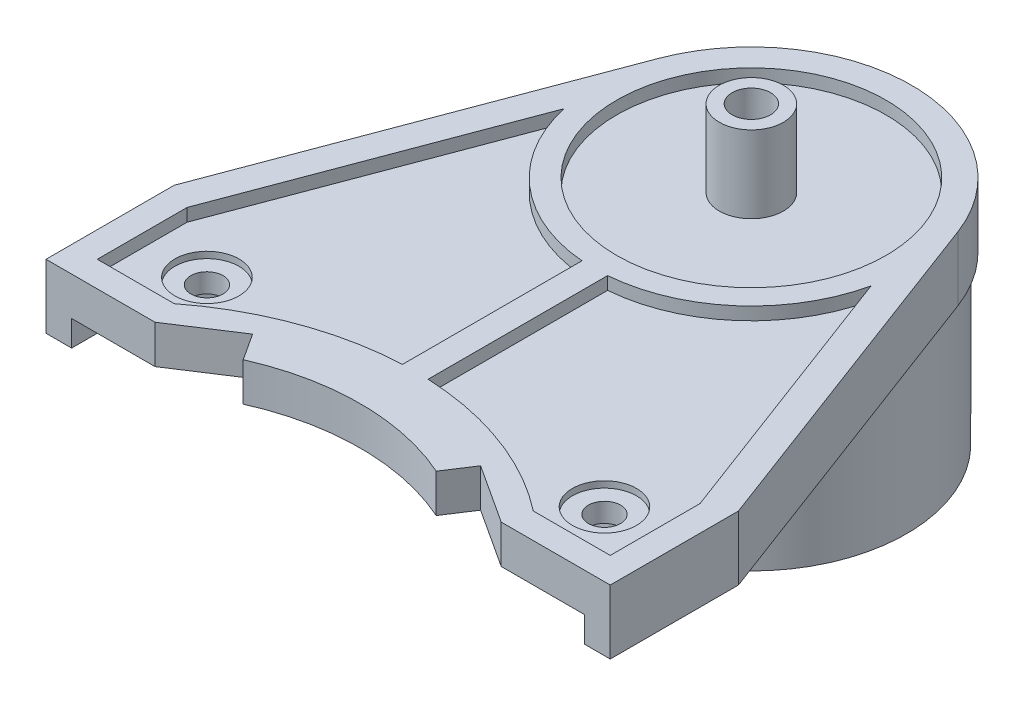
from build123d import *

# Parameters (mm, degrees)
BOSS_EXTRUDE1_DEPTH = 5
SKETCH3_R           = 10.5
CUT_EXTRUDE1_DEPTH  = 1
SKETCH4_R           = 2.5
BOSS_EXTRUDE2_DEPTH = 6
SKETCH5_R           = 1.5
CUT_EXTRUDE2_DEPTH  = 3
CUT_EXTRUDE3_DEPTH  = 1
SKETCH7_R           = 1.25
CUT_EXTRUDE4_DEPTH  = 5
SKETCH8_R           = 2.5
CUT_EXTRUDE5_DEPTH  = 0.5
CUT_EXTRUDE6_DEPTH  = 2
CUT_EXTRUDE7_DEPTH  = 2
SKETCH12_R          = 12.1
BOSS_EXTRUDE3_DEPTH = 15
SKETCH13_R          = 10.4
SKETCH13_R_2        = 2.5
CUT_EXTRUDE8_DEPTH  = 14
SKETCH14_R          = 1.5
CUT_EXTRUDE9_DEPTH  = 5


with BuildPart() as part:
    # Sketch1 → Boss-Extrude1 (new body)
    with BuildSketch(Plane(origin=(0, 0, 0), x_dir=(1, 0, 0), z_dir=(0, 1, 0))):
        with BuildLine():
            Line((-22, -23.004932369), (-22, -33.004932369))
            Line((-22, -33.004932369), (-13.5, -33.004932369))
            Line((-13.5, -33.004932369), (-8.890227771, -30.004932369))
            Line((-8.890227771, -30.004932369), (-7.526591408, -32.100283382))
            ThreePointArc((-7.526591408, -32.100283382), (-3.847417482, -30.904492858), (0, -30.5))
            Line((0, -30.5), (0, 12.5))
            ThreePointArc((0, 12.5), (-7.116131574, 10.276705281), (-11.700861907, 4.397707428))
            Line((-11.700861907, 4.397707428), (-22, -23.004932369))
        make_face()
        with BuildLine():
            ThreePointArc((11.700861907, 4.397707428), (7.116131574, 10.276705281), (0, 12.5))
            Line((0, 12.5), (0, -30.5))
            ThreePointArc((0, -30.5), (3.847417482, -30.904492858), (7.526591408, -32.100283382))
            Line((7.526591408, -32.100283382), (8.890227771, -30.004932369))
            Line((8.890227771, -30.004932369), (13.5, -33.004932369))
            Line((13.5, -33.004932369), (22, -33.004932369))
            Line((22, -33.004932369), (22, -23.004932369))
            Line((22, -23.004932369), (11.700861907, 4.397707428))
        make_face()
    extrude(amount=BOSS_EXTRUDE1_DEPTH)

    # Sketch3 → Cut-Extrude1 (cut)
    with BuildSketch(Plane(origin=(0, 5, 0), x_dir=(1, 0, 0), z_dir=(0, 1, 0))):
        Circle(SKETCH3_R)
    extrude(amount=-CUT_EXTRUDE1_DEPTH, mode=Mode.SUBTRACT)

    # Sketch4 → Boss-Extrude2 (add)
    with BuildSketch(Plane(origin=(0, 4, 0), x_dir=(1, 0, 0), z_dir=(0, 1, 0))):
        Circle(SKETCH4_R)
    extrude(amount=BOSS_EXTRUDE2_DEPTH)

    # Sketch5 → Cut-Extrude2 (cut)
    with BuildSketch(Plane(origin=(0, 10, 0), x_dir=(1, 0, 0), z_dir=(0, 1, 0))):
        Circle(SKETCH5_R)
    extrude(amount=-CUT_EXTRUDE2_DEPTH, mode=Mode.SUBTRACT)

    # Sketch6 → Cut-Extrude3 (cut)
    with BuildSketch(Plane(origin=(0, 5, 0), x_dir=(1, 0, 0), z_dir=(0, 1, 0))):
        with BuildLine():
            Line((-1, -12.209115447), (-1, -26.209115447))
            ThreePointArc((-1, -26.209115447), (-7.874005651, -27.593208423), (-14, -31.004932369))
            Line((-14, -31.004932369), (-20, -31.004932369))
            Line((-20, -31.004932369), (-20, -24.004932369))
            Line((-20, -24.004932369), (-11.96508369, -2.626646587))
            ThreePointArc((-11.96508369, -2.626646587), (-8.060972406, -9.224056801), (-1, -12.209115447))
        make_face()
        with BuildLine():
            Line((20, -24.004932369), (11.96508369, -2.626646587))
            ThreePointArc((11.96508369, -2.626646587), (8.060972406, -9.224056801), (1, -12.209115447))
            Line((1, -12.209115447), (1, -26.209115447))
            ThreePointArc((1, -26.209115447), (7.874005651, -27.593208423), (14, -31.004932369))
            Line((14, -31.004932369), (20, -31.004932369))
            Line((20, -31.004932369), (20, -24.004932369))
        make_face()
    extrude(amount=-CUT_EXTRUDE3_DEPTH, mode=Mode.SUBTRACT)

    # Sketch7 → Cut-Extrude4 (cut, through all)
    with BuildSketch(Plane(origin=(0, 4, 0), x_dir=(1, 0, 0), z_dir=(0, 1, 0))):
        with Locations((-15.5, -26.954932369)):
            Circle(SKETCH7_R)
        with Locations((15.5, -26.954932369)):
            Circle(SKETCH7_R)
    extrude(amount=-CUT_EXTRUDE4_DEPTH, mode=Mode.SUBTRACT)

    # Sketch8 → Cut-Extrude5 (cut)
    with BuildSketch(Plane(origin=(0, 4, 0), x_dir=(1, 0, 0), z_dir=(0, 1, 0))):
        with Locations((-15.5, -26.954932369)):
            Circle(SKETCH8_R)
        with Locations((15.5, -26.954932369)):
            Circle(SKETCH8_R)
    extrude(amount=-CUT_EXTRUDE5_DEPTH, mode=Mode.SUBTRACT)

    # Sketch9 → Cut-Extrude6 (cut)
    with BuildSketch(Plane.XZ):
        with BuildLine():
            Line((20, 33.004932369), (20, 27.004932369))
            ThreePointArc((20, 27.004932369), (0, 18), (-20, 27.004932369))
            Line((-20, 27.004932369), (-20, 33.004932369))
            Line((-20, 33.004932369), (20, 33.004932369))
        make_face()
    extrude(amount=-CUT_EXTRUDE6_DEPTH, mode=Mode.SUBTRACT)

    # Sketch11 → Cut-Extrude7 (cut)
    with BuildSketch(Plane.XZ):
        with BuildLine():
            Line((-20, 23.004932369), (-10.073125454, -3.40723582))
            ThreePointArc((-10.073125454, -3.40723582), (0, -10.633772254), (10.073125454, -3.40723582))
            Line((10.073125454, -3.40723582), (20, 23.004932369))
            Line((20, 23.004932369), (20, 25.529642354))
            ThreePointArc((20, 25.529642354), (0, 17.000016389), (-20, 25.529642354))
            Line((-20, 25.529642354), (-20, 23.004932369))
        make_face()
    extrude(amount=-CUT_EXTRUDE7_DEPTH, mode=Mode.SUBTRACT)

    # Sketch12 → Boss-Extrude3 (add)
    with BuildSketch(Plane.XZ.offset(-2)):
        Circle(SKETCH12_R)
    extrude(amount=BOSS_EXTRUDE3_DEPTH)

    # Sketch13 → Cut-Extrude8 (cut)
    with BuildSketch(Plane.XZ.offset(13)):
        Circle(SKETCH13_R)
        Circle(SKETCH13_R_2, mode=Mode.SUBTRACT)
    extrude(amount=-CUT_EXTRUDE8_DEPTH, mode=Mode.SUBTRACT)

    # Sketch14 → Cut-Extrude9 (cut)
    with BuildSketch(Plane.XZ.offset(13)):
        Circle(SKETCH14_R)
    extrude(amount=-CUT_EXTRUDE9_DEPTH, mode=Mode.SUBTRACT)


solid = part.part
